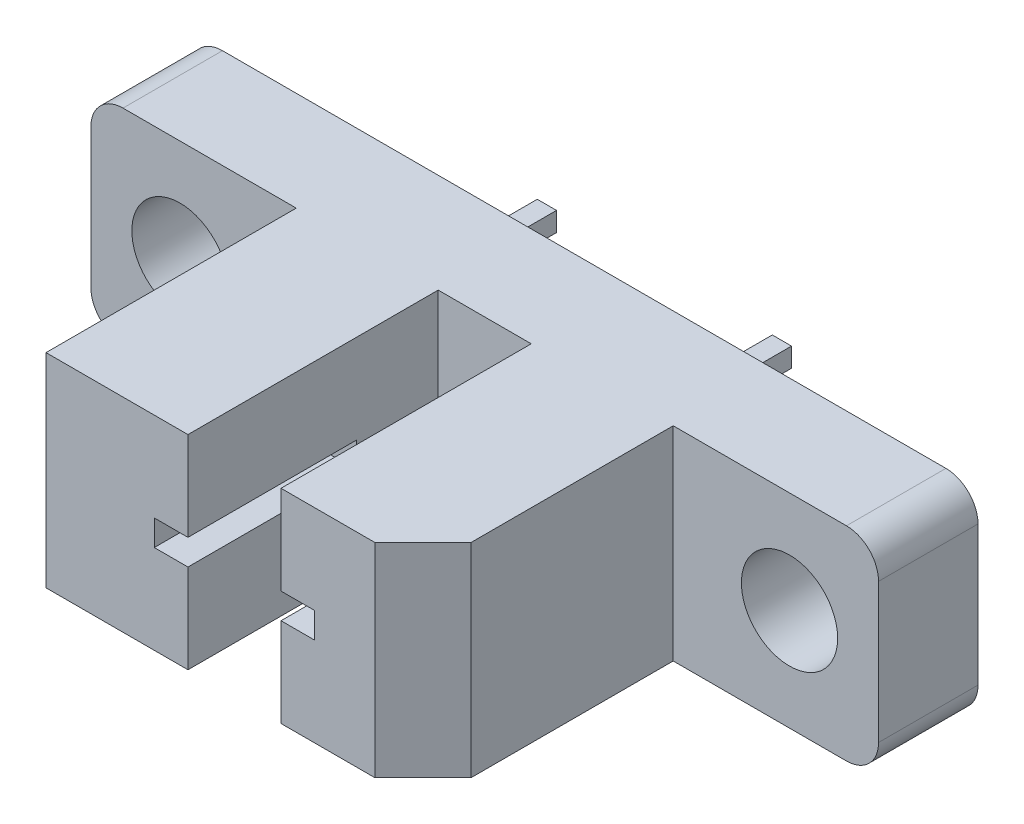
from build123d import *

# Parameters (mm, degrees)
ESBO_O1_W                 = 24.55
ESBO_O1_H                 = 6.35
ESBO_O1_R                 = 1.5
RESSALTO_EXTRUS_O1_DEPTH  = 3.1
ESBO_O2_W                 = 11.75
ESBO_O2_H                 = 6.35
RESSALTO_EXTRUS_O2_DEPTH  = 7.8
ESBO_O5_W                 = 5
ESBO_O5_H                 = 0.8
CORTE_EXTRUS_O2_DEPTH     = 5.25
ESBO_O3_W                 = 2.9
ESBO_O3_H                 = 6.35
CORTE_EXTRUS_O1_DEPTH     = 7.8
CHANFRO3_SIZE             = 1.5
FILETE1_R                 = 1
ESBO_O9_W                 = 0.6
ESBO_O9_H                 = 0.6
RESSALTO_EXTRUS_O3_DEPTH  = 2.5
ESPELHAR2_COPY_1_SKETCH_W = 0.6
ESPELHAR2_COPY_1_SKETCH_H = 0.6
ESPELHAR2_COPY_1_DEPTH    = 2.5


with BuildPart() as part:
    # Esboço1 → Ressalto-extrusão1 (new body)
    with BuildSketch(Plane.XY):
        Rectangle(ESBO_O1_W, ESBO_O1_H)
        with Locations((-9.5, 0)):
            Circle(ESBO_O1_R, mode=Mode.SUBTRACT)
        with Locations((9.5, 0)):
            Circle(ESBO_O1_R, mode=Mode.SUBTRACT)
    extrude(amount=RESSALTO_EXTRUS_O1_DEPTH)

    # Esboço2 → Ressalto-extrusão2 (add)
    with BuildSketch(Plane.XY.offset(3.1)):
        Rectangle(ESBO_O2_W, ESBO_O2_H)
    extrude(amount=RESSALTO_EXTRUS_O2_DEPTH)

    # Esboço5 → Corte-extrusão2 (cut)
    with BuildSketch(Plane.XY.offset(10.9)):
        Rectangle(ESBO_O5_W, ESBO_O5_H)
    extrude(amount=-CORTE_EXTRUS_O2_DEPTH, mode=Mode.SUBTRACT)

    # Esboço3 → Corte-extrusão1 (cut)
    with BuildSketch(Plane.XY.offset(10.9)):
        Rectangle(ESBO_O3_W, ESBO_O3_H)
    extrude(amount=-CORTE_EXTRUS_O1_DEPTH, mode=Mode.SUBTRACT)

    # Chanfro3
    chanfro3_edges = [part.edges().sort_by_distance(p)[0] for p in [
        (5.875, 0, 10.9),
    ]]
    chamfer(chanfro3_edges, length=CHANFRO3_SIZE)

    # Filete1
    filete1_edges = [part.edges().sort_by_distance(p)[0] for p in [
        (12.275, -3.175, 1.55),
        (-12.275, -3.175, 1.55),
        (-12.275, 3.175, 1.55),
        (12.275, 3.175, 1.55),
    ]]
    fillet(filete1_edges, radius=FILETE1_R)

    # Esboço9 → Ressalto-extrusão3 (add)
    with BuildSketch(Plane(origin=(0, 0, 0), x_dir=(-1, 0, 0), z_dir=(0, 0, -1))):
        with Locations((-3.6625, 1.27)):
            Rectangle(ESBO_O9_W, ESBO_O9_H)
    ressalto_extrus_o3 = extrude(amount=RESSALTO_EXTRUS_O3_DEPTH)

    # Espelhar1: Ressalto-extrusão3 across plane
    add(ressalto_extrus_o3.mirror(Plane.ZX))

    # Espelhar2: Ressalto-extrusão3 across plane
    add(ressalto_extrus_o3.mirror(Plane.ZY))

    # Espelhar2 copy 1 sketch → Espelhar2 copy 1 (add)
    with BuildSketch(Plane(origin=(0, 0, 0), x_dir=(1, 0, 0), z_dir=(0, 0, -1))):
        with Locations((-3.6625, 1.27)):
            Rectangle(ESPELHAR2_COPY_1_SKETCH_W, ESPELHAR2_COPY_1_SKETCH_H)
    extrude(amount=ESPELHAR2_COPY_1_DEPTH)


solid = part.part
